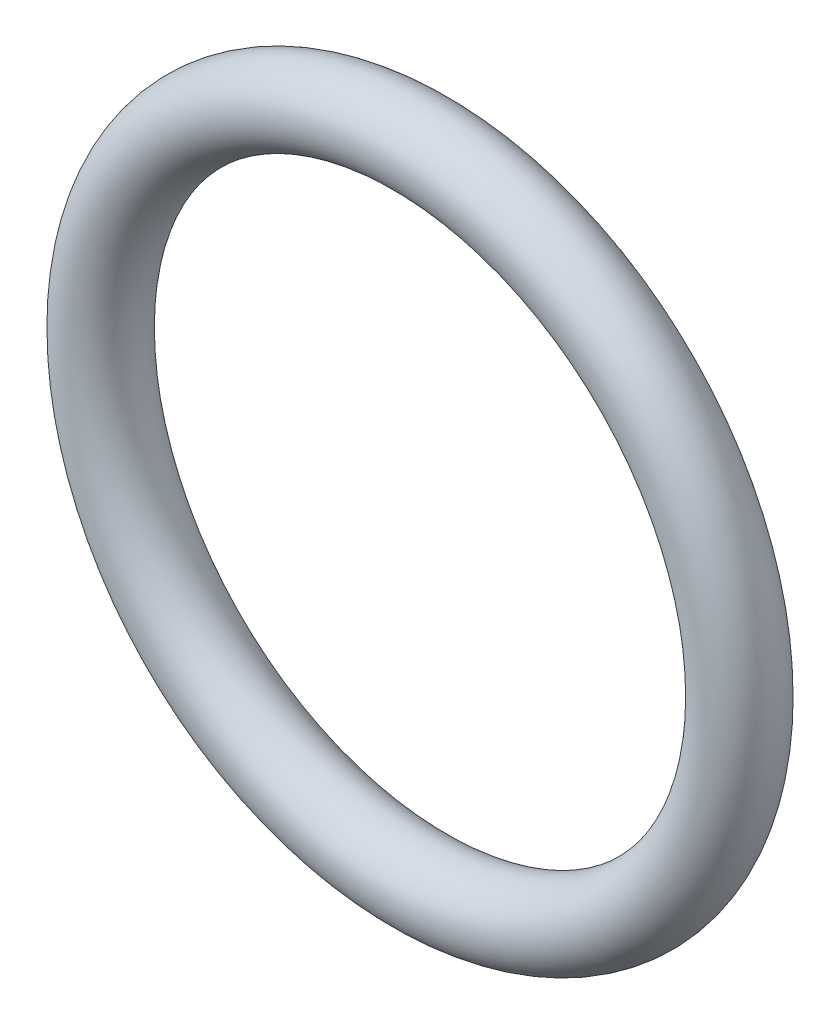
from build123d import *

# Parameters (mm, degrees)
SKETCH1_R = 1.1049


with BuildPart() as part:
    # Sketch1 → Revolve1 (revolve)
    with BuildSketch(Plane(origin=(0, 0, 0), x_dir=(0, -1, 0), z_dir=(1, 0, 0))):
        with Locations((9.2837, 0)):
            Circle(SKETCH1_R)
    revolve(axis=Axis((0, 0, 1.1049), (0, 0, -1)))


solid = part.part
